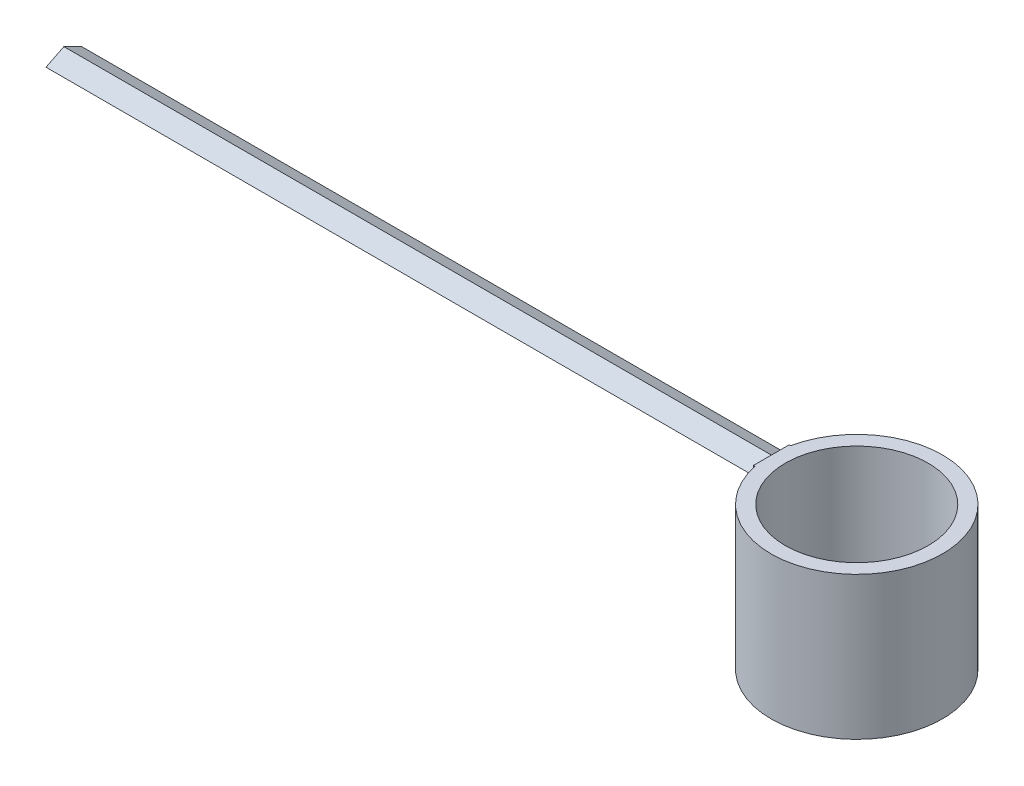
from build123d import *

# Parameters (mm, degrees)
SKETCH1_R           = 1.2
SKETCH1_R_2         = 1
BOSS_EXTRUDE1_DEPTH = 2
BOSS_EXTRUDE3_DEPTH = 0.25
SKETCH3_OUTSIDE_W   = 6.938
SKETCH3_OUTSIDE_H   = 6.538
CUT_EXTRUDE3_DEPTH  = 9.9


with BuildPart() as part:
    # Sketch1 → Boss-Extrude1 (new body)
    with BuildSketch(Plane(origin=(0, 0, 0), x_dir=(1, 0, 0), z_dir=(0, 1, 0))):
        Circle(SKETCH1_R)
        Circle(SKETCH1_R_2, mode=Mode.SUBTRACT)
    extrude(amount=BOSS_EXTRUDE1_DEPTH)

    # Sketch2 → Boss-Extrude3 (add)
    with BuildSketch(Plane(origin=(0, 2, 0), x_dir=(1, 0, 0), z_dir=(0, 1, 0))):
        with BuildLine():
            Line((-11.094706331, -0.25), (-1.173669459, -0.25))
            ThreePointArc((-1.173669459, -0.25), (-1.2, 0), (-1.173669459, 0.25))
            Line((-1.173669459, 0.25), (-11.094706331, 0.25))
            Line((-11.094706331, 0.25), (-11.094706331, -0.25))
        make_face()
    extrude(amount=-BOSS_EXTRUDE3_DEPTH)

    # Sketch3 outside → Cut-Extrude3 (cut)
    with BuildSketch(Plane.ZY.offset(11.094706331)):
        with Locations((0, 1)):
            Rectangle(SKETCH3_OUTSIDE_W, SKETCH3_OUTSIDE_H)
        Polygon((-0.25, 1.875), (0, 2), (0.25, 1.875), (0, 1.75), align=None, mode=Mode.SUBTRACT)
    extrude(amount=-CUT_EXTRUDE3_DEPTH, mode=Mode.SUBTRACT)


solid = part.part
